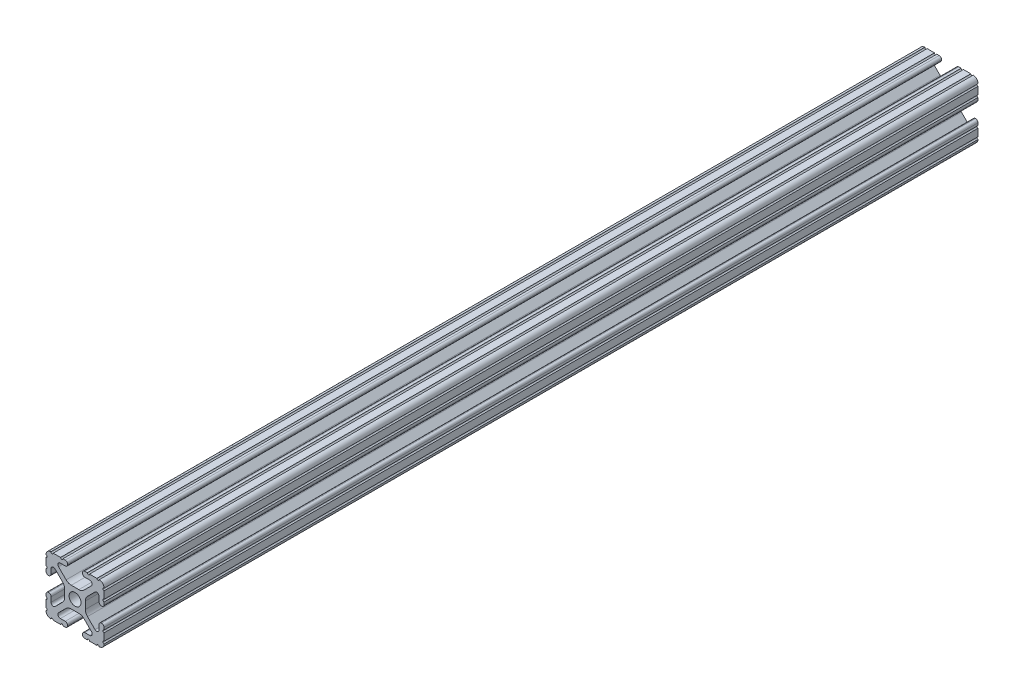
from build123d import *

# Parameters (mm, degrees)
SKETCH1_R           = 2.6035
BOSS_EXTRUDE1_DEPTH = 304.8
SKETCH2_W           = 33.577347781
SKETCH2_H           = 32.744851555
CUT_EXTRUDE1_DEPTH  = 227.33


with BuildPart() as part:
    # Sketch1 → Boss-Extrude1 (new body, symmetric)
    with BuildSketch(Plane.XY):
        with BuildLine():
            Line((-7.179650497, -8.645192506), (-3.952270251, -5.423690499))
            ThreePointArc((-3.952270251, -5.423690499), (-2.922936451, -4.736929036), (-1.709253557, -4.4958))
            Line((-1.709253557, -4.4958), (1.709253557, -4.4958))
            ThreePointArc((1.709253557, -4.4958), (2.922936451, -4.736929036), (3.952270251, -5.423690499))
            Line((3.952270251, -5.423690499), (7.179650497, -8.645192506))
            ThreePointArc((7.179650497, -8.645192506), (7.41473083, -9.822813117), (6.416408329, -10.4902))
            Line((6.416408329, -10.4902), (4.287512407, -10.4902))
            ThreePointArc((4.287512407, -10.4902), (3.54574862, -10.79744862), (3.2385, -11.539212407))
            Line((3.2385, -11.539212407), (3.2385, -11.650987593))
            ThreePointArc((3.2385, -11.650987593), (3.54574862, -12.39275138), (4.287512407, -12.7))
            Line((4.287512407, -12.7), (5.317126718, -12.7))
            ThreePointArc((5.317126718, -12.7), (5.825126718, -12.192), (6.333126718, -12.7))
            Line((6.333126718, -12.7), (9.550443118, -12.7))
            ThreePointArc((9.550443118, -12.7), (10.058366869, -12.192000006), (10.566443095, -12.699847501))
            ThreePointArc((10.566443095, -12.699847501), (12.082537762, -12.08250727), (12.699846982, -10.566399977))
            ThreePointArc((12.699846982, -10.566399977), (12.192000006, -10.058323491), (12.7, -9.5504))
            Line((12.7, -9.5504), (12.7, -6.3330836))
            ThreePointArc((12.7, -6.3330836), (12.192, -5.8250836), (12.7, -5.3170836))
            Line((12.7, -5.3170836), (12.7, -4.287469289))
            ThreePointArc((12.7, -4.287469289), (12.39275138, -3.545705502), (11.650987593, -3.238456882))
            Line((11.650987593, -3.238456882), (11.539212407, -3.238456882))
            ThreePointArc((11.539212407, -3.238456882), (10.79744862, -3.545705502), (10.4902, -4.287469289))
            Line((10.4902, -4.287469289), (10.4902, -6.402089023))
            ThreePointArc((10.4902, -6.402089023), (9.856505071, -7.351067942), (8.737131347, -7.129408934))
            Line((8.737131347, -7.129408934), (5.441005833, -3.840816462))
            ThreePointArc((5.441005833, -3.840816462), (4.750877967, -2.809883091), (4.5085, -1.593185507))
            Line((4.5085, -1.593185507), (4.5085, 1.593185507))
            ThreePointArc((4.5085, 1.593185507), (4.750877967, 2.809883091), (5.441005833, 3.840816462))
            Line((5.441005833, 3.840816462), (8.737131347, 7.129408934))
            ThreePointArc((8.737131347, 7.129408934), (9.856505071, 7.351067942), (10.4902, 6.402089023))
            Line((10.4902, 6.402089023), (10.4902, 4.287469289))
            ThreePointArc((10.4902, 4.287469289), (10.79744862, 3.545705502), (11.539212407, 3.238456882))
            Line((11.539212407, 3.238456882), (11.650987593, 3.238456882))
            ThreePointArc((11.650987593, 3.238456882), (12.39275138, 3.545705502), (12.7, 4.287469289))
            Line((12.7, 4.287469289), (12.7, 5.3170836))
            ThreePointArc((12.7, 5.3170836), (12.192, 5.8250836), (12.7, 6.3330836))
            Line((12.7, 6.3330836), (12.7, 9.5504))
            ThreePointArc((12.7, 9.5504), (12.192000006, 10.058323491), (12.699846982, 10.566399977))
            ThreePointArc((12.699846982, 10.566399977), (12.082537762, 12.08250727), (10.566443095, 12.699847501))
            ThreePointArc((10.566443095, 12.699847501), (10.058366869, 12.192000006), (9.550443118, 12.7))
            Line((9.550443118, 12.7), (6.333126718, 12.7))
            ThreePointArc((6.333126718, 12.7), (5.825126718, 12.192), (5.317126718, 12.7))
            Line((5.317126718, 12.7), (4.287512407, 12.7))
            ThreePointArc((4.287512407, 12.7), (3.54574862, 12.39275138), (3.2385, 11.650987593))
            Line((3.2385, 11.650987593), (3.2385, 11.539212407))
            ThreePointArc((3.2385, 11.539212407), (3.54574862, 10.79744862), (4.287512407, 10.4902))
            Line((4.287512407, 10.4902), (6.476788598, 10.4902))
            ThreePointArc((6.476788598, 10.4902), (7.432222385, 9.85140422), (7.207036008, 8.724370562))
            Line((7.207036008, 8.724370562), (3.898272566, 5.423169045))
            ThreePointArc((3.898272566, 5.423169045), (2.869120213, 4.736787962), (1.655778399, 4.4958))
            Line((1.655778399, 4.4958), (-1.655778399, 4.4958))
            ThreePointArc((-1.655778399, 4.4958), (-2.869120213, 4.736787962), (-3.898272566, 5.423169045))
            Line((-3.898272566, 5.423169045), (-7.207036008, 8.724370562))
            ThreePointArc((-7.207036008, 8.724370562), (-7.432222385, 9.85140422), (-6.476788598, 10.4902))
            Line((-6.476788598, 10.4902), (-4.287512407, 10.4902))
            ThreePointArc((-4.287512407, 10.4902), (-3.54574862, 10.79744862), (-3.2385, 11.539212407))
            Line((-3.2385, 11.539212407), (-3.2385, 11.650987593))
            ThreePointArc((-3.2385, 11.650987593), (-3.54574862, 12.39275138), (-4.287512407, 12.7))
            Line((-4.287512407, 12.7), (-5.317126718, 12.7))
            ThreePointArc((-5.317126718, 12.7), (-5.825126718, 12.192), (-6.333126718, 12.7))
            Line((-6.333126718, 12.7), (-9.550443118, 12.7))
            ThreePointArc((-9.550443118, 12.7), (-10.058366869, 12.192000006), (-10.566443095, 12.699847501))
            ThreePointArc((-10.566443095, 12.699847501), (-12.082537762, 12.08250727), (-12.699846982, 10.566399977))
            ThreePointArc((-12.699846982, 10.566399977), (-12.192000006, 10.058323491), (-12.7, 9.5504))
            Line((-12.7, 9.5504), (-12.7, 6.3330836))
            ThreePointArc((-12.7, 6.3330836), (-12.192, 5.8250836), (-12.7, 5.3170836))
            Line((-12.7, 5.3170836), (-12.7, 4.287469289))
            ThreePointArc((-12.7, 4.287469289), (-12.39275138, 3.545705502), (-11.650987593, 3.238456882))
            Line((-11.650987593, 3.238456882), (-11.539212407, 3.238456882))
            ThreePointArc((-11.539212407, 3.238456882), (-10.79744862, 3.545705502), (-10.4902, 4.287469289))
            Line((-10.4902, 4.287469289), (-10.4902, 6.402089023))
            ThreePointArc((-10.4902, 6.402089023), (-9.856505071, 7.351067942), (-8.737131347, 7.129408934))
            Line((-8.737131347, 7.129408934), (-5.441005833, 3.840816462))
            ThreePointArc((-5.441005833, 3.840816462), (-4.750877967, 2.809883091), (-4.5085, 1.593185507))
            Line((-4.5085, 1.593185507), (-4.5085, -1.593185507))
            ThreePointArc((-4.5085, -1.593185507), (-4.750877967, -2.809883091), (-5.441005833, -3.840816462))
            Line((-5.441005833, -3.840816462), (-8.737131347, -7.129408934))
            ThreePointArc((-8.737131347, -7.129408934), (-9.856505071, -7.351067942), (-10.4902, -6.402089023))
            Line((-10.4902, -6.402089023), (-10.4902, -4.287469289))
            ThreePointArc((-10.4902, -4.287469289), (-10.79744862, -3.545705502), (-11.539212407, -3.238456882))
            Line((-11.539212407, -3.238456882), (-11.650987593, -3.238456882))
            ThreePointArc((-11.650987593, -3.238456882), (-12.39275138, -3.545705502), (-12.7, -4.287469289))
            Line((-12.7, -4.287469289), (-12.7, -5.3170836))
            ThreePointArc((-12.7, -5.3170836), (-12.192, -5.8250836), (-12.7, -6.3330836))
            Line((-12.7, -6.3330836), (-12.7, -9.5504))
            ThreePointArc((-12.7, -9.5504), (-12.192000006, -10.058323491), (-12.699846982, -10.566399977))
            ThreePointArc((-12.699846982, -10.566399977), (-12.082537762, -12.08250727), (-10.566443095, -12.699847501))
            ThreePointArc((-10.566443095, -12.699847501), (-10.058366869, -12.192000006), (-9.550443118, -12.7))
            Line((-9.550443118, -12.7), (-6.333126718, -12.7))
            ThreePointArc((-6.333126718, -12.7), (-5.825126718, -12.192), (-5.317126718, -12.7))
            Line((-5.317126718, -12.7), (-4.287512407, -12.7))
            ThreePointArc((-4.287512407, -12.7), (-3.54574862, -12.39275138), (-3.2385, -11.650987593))
            Line((-3.2385, -11.650987593), (-3.2385, -11.539212407))
            ThreePointArc((-3.2385, -11.539212407), (-3.54574862, -10.79744862), (-4.287512407, -10.4902))
            Line((-4.287512407, -10.4902), (-6.416408329, -10.4902))
            ThreePointArc((-6.416408329, -10.4902), (-7.41473083, -9.822813117), (-7.179650497, -8.645192506))
        make_face()
        Circle(SKETCH1_R, mode=Mode.SUBTRACT)
    extrude(amount=BOSS_EXTRUDE1_DEPTH, both=True)

    # Sketch2 → Cut-Extrude1 (cut)
    with BuildSketch(Plane.XY.offset(304.8)):
        with Locations((0.601247275, -1.572492872)):
            Rectangle(SKETCH2_W, SKETCH2_H)
    extrude(amount=-CUT_EXTRUDE1_DEPTH, mode=Mode.SUBTRACT)


solid = part.part
